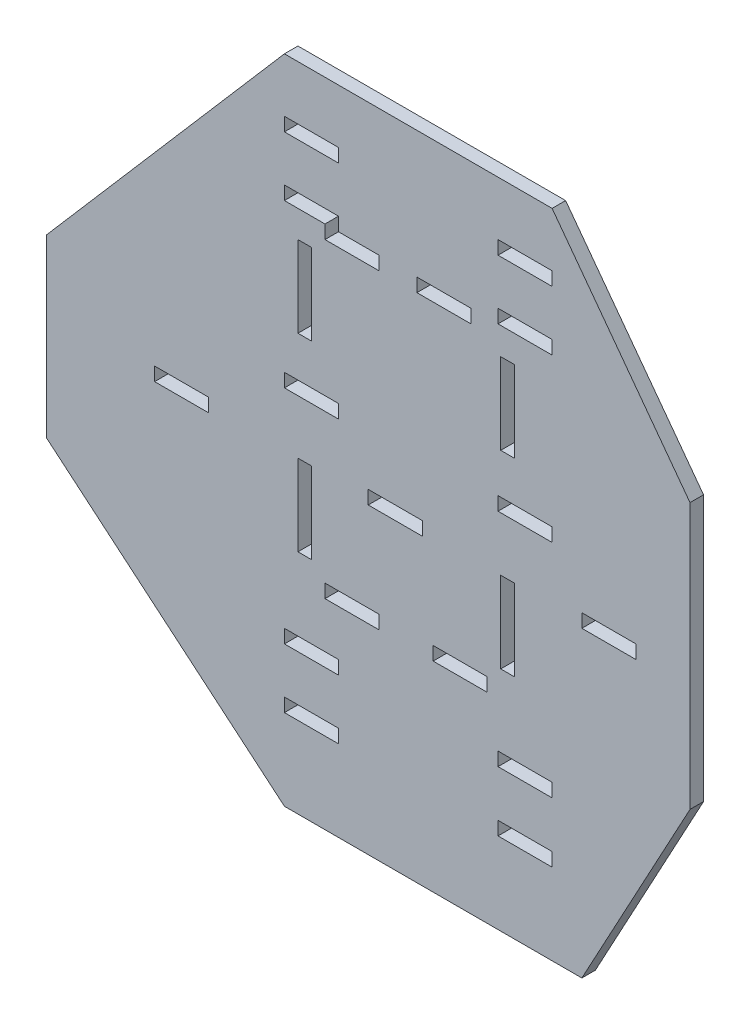
from build123d import *

# Parameters (mm, degrees)
SKETCH1_W           = 20
SKETCH1_H           = 5
SKETCH1_W_2         = 5
SKETCH1_H_2         = 30
BOSS_EXTRUDE1_DEPTH = 5


with BuildPart() as part:
    # Sketch1 → Boss-Extrude1 (new body)
    with BuildSketch(Plane.XY):
        Polygon((85, -102.314739042), (85, -4.053866158), (34, 64.685260958), (-65, 64.685260958), (-153, -37.314739042), (-153, -102.314739042), (-65, -176.314739042), (45, -176.314739042), align=None)
        with Locations((-55, -143.814739042)):
            Rectangle(SKETCH1_W, SKETCH1_H, mode=Mode.SUBTRACT)
        with Locations((-55, -121.814739042)):
            Rectangle(SKETCH1_W, SKETCH1_H, mode=Mode.SUBTRACT)
        with Locations((-103, -61.814739042)):
            Rectangle(SKETCH1_W, SKETCH1_H, mode=Mode.SUBTRACT)
        with Locations((-40, -99.814739042)):
            Rectangle(SKETCH1_W, SKETCH1_H, mode=Mode.SUBTRACT)
        with Locations((-57.5, -77.314739042)):
            Rectangle(SKETCH1_W_2, SKETCH1_H_2, mode=Mode.SUBTRACT)
        with Locations((24, -143.814739042)):
            Rectangle(SKETCH1_W, SKETCH1_H, mode=Mode.SUBTRACT)
        with Locations((24, -121.622499161)):
            Rectangle(SKETCH1_W, SKETCH1_H, mode=Mode.SUBTRACT)
        with Locations((0, -99.814739042)):
            Rectangle(SKETCH1_W, SKETCH1_H, mode=Mode.SUBTRACT)
        with Locations((-24, -61.814739042)):
            Rectangle(SKETCH1_W, SKETCH1_H, mode=Mode.SUBTRACT)
        with Locations((17.5, -77.314739042)):
            Rectangle(SKETCH1_W_2, SKETCH1_H_2, mode=Mode.SUBTRACT)
        with Locations((55, -61.814739042)):
            Rectangle(SKETCH1_W, SKETCH1_H, mode=Mode.SUBTRACT)
        with Locations((-55, -39.814739042)):
            Rectangle(SKETCH1_W, SKETCH1_H, mode=Mode.SUBTRACT)
        with Locations((-57.5, -7.314739042)):
            Rectangle(SKETCH1_W_2, SKETCH1_H_2, mode=Mode.SUBTRACT)
        Polygon((-65, 22.685260958), (-45, 22.685260958), (-45, 17.685260958), (-30, 17.685260958), (-30, 12.685260958), (-50, 12.685260958), (-50, 17.685260958), (-65, 17.685260958), align=None, mode=Mode.SUBTRACT)
        with Locations((-55, 42.185260958)):
            Rectangle(SKETCH1_W, SKETCH1_H, mode=Mode.SUBTRACT)
        with Locations((24, -39.814739042)):
            Rectangle(SKETCH1_W, SKETCH1_H, mode=Mode.SUBTRACT)
        with Locations((17.5, -7.314739042)):
            Rectangle(SKETCH1_W_2, SKETCH1_H_2, mode=Mode.SUBTRACT)
        with Locations((-6, 15.185260958)):
            Rectangle(SKETCH1_W, SKETCH1_H, mode=Mode.SUBTRACT)
        with Locations((24, 20.185260958)):
            Rectangle(SKETCH1_W, SKETCH1_H, mode=Mode.SUBTRACT)
        with Locations((24, 42.185260958)):
            Rectangle(SKETCH1_W, SKETCH1_H, mode=Mode.SUBTRACT)
    extrude(amount=BOSS_EXTRUDE1_DEPTH)


solid = part.part
